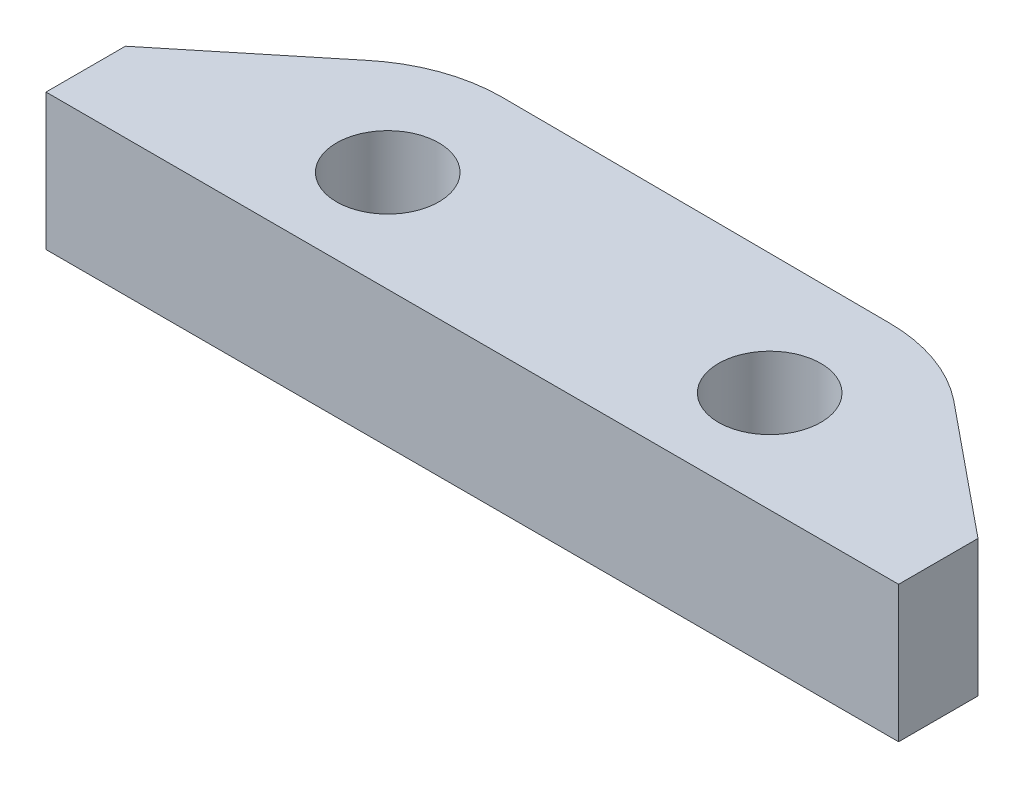
from build123d import *

# Parameters (mm, degrees)
CROQUIS1_R              = 1.499999985
CROQUIS1_R_2            = 1.499999871
SALIENTE_EXTRUIR1_DEPTH = 4


with BuildPart() as part:
    # Croquis1 → Saliente-Extruir1 (new body)
    with BuildSketch(Plane(origin=(0, 0, 0), x_dir=(1, 0, 0), z_dir=(0, 1, 0))):
        with BuildLine():
            Line((-12.499997978, -1.290428922), (-12.499997978, -3.618590638))
            Line((-12.499997978, -3.618590638), (12.500000954, -3.618590638))
            Line((12.500000954, -3.618590638), (12.500000954, -1.290428922))
            Line((12.500000954, -1.290428922), (8.627905846, 1.868327334))
            ThreePointArc((8.627905846, 1.868327334), (7.259690403, 2.621201307), (5.71991749, 2.881839161))
            Line((5.71991749, 2.881839161), (-5.687424356, 2.937856323))
            ThreePointArc((-5.687424356, 2.937856323), (-7.251897096, 2.662171308), (-8.627901793, 1.868327334))
            Line((-8.627901793, 1.868327334), (-12.499997978, -1.290428922))
        make_face()
        with Locations((-5.449998151, -0.648590639)):
            Circle(CROQUIS1_R, mode=Mode.SUBTRACT)
        with Locations((5.750001083, -0.64859061)):
            Circle(CROQUIS1_R_2, mode=Mode.SUBTRACT)
    extrude(amount=SALIENTE_EXTRUIR1_DEPTH)


solid = part.part
